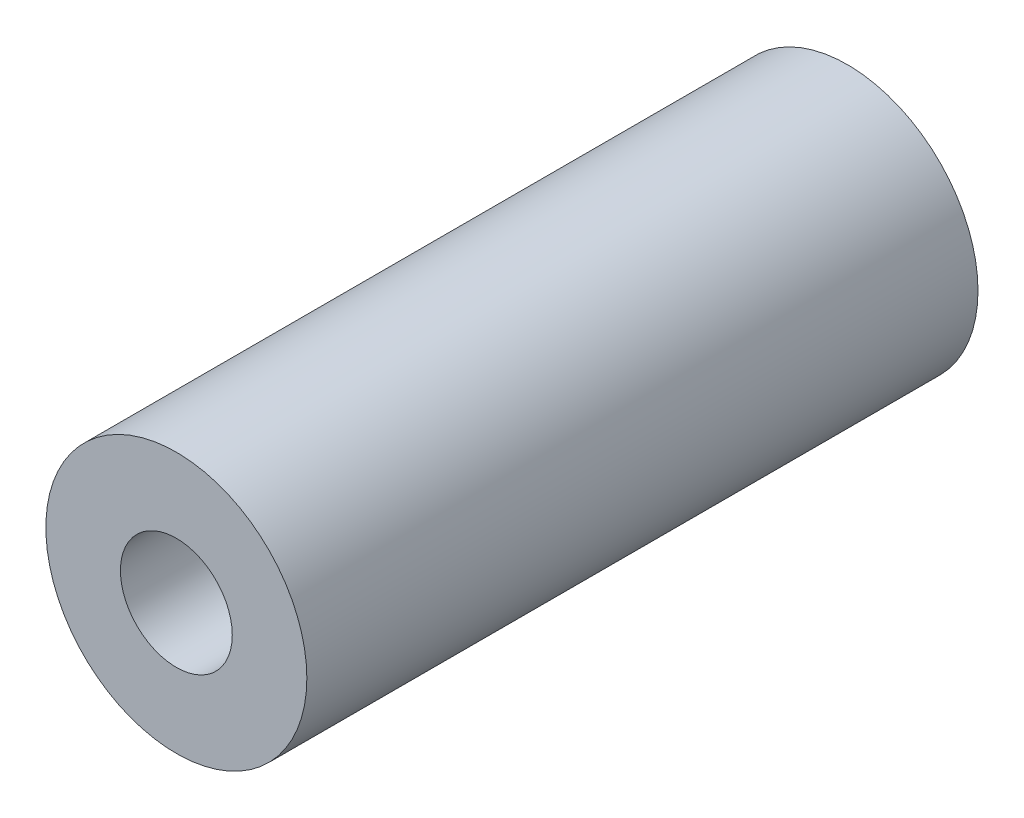
from build123d import *

# Parameters (mm, degrees)
SKETCH1_R           = 11.1125
SKETCH1_R_2         = 4.7625
BOSS_EXTRUDE1_DEPTH = 57.15


with BuildPart() as part:
    # Sketch1 → Boss-Extrude1 (new body)
    with BuildSketch(Plane.XY):
        Circle(SKETCH1_R)
        Circle(SKETCH1_R_2, mode=Mode.SUBTRACT)
    extrude(amount=BOSS_EXTRUDE1_DEPTH)


solid = part.part
